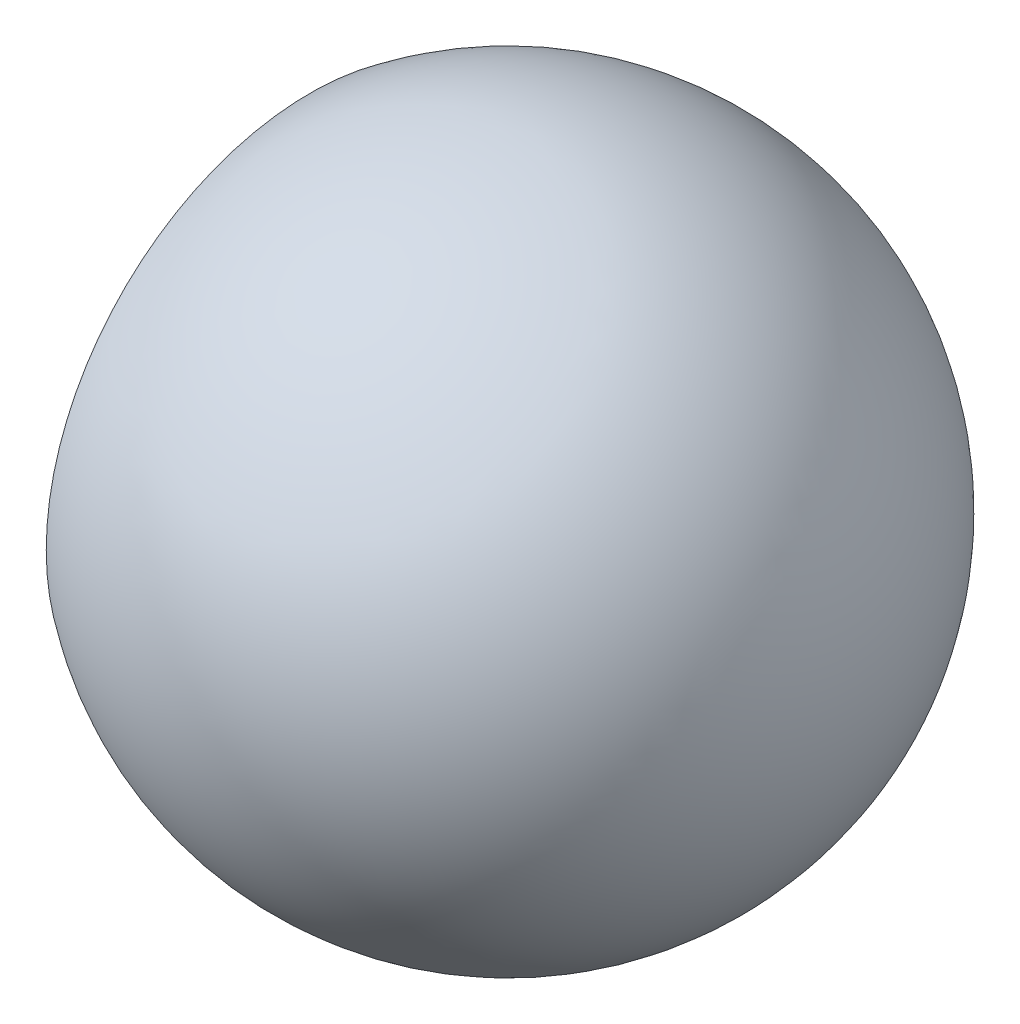
from build123d import *


with BuildPart() as part:
    # Эскиз5 → Повернуть2 (revolve)
    with BuildSketch(Plane.XY):
        with BuildLine():
            Line((0, 0), (10, 0))
            ThreePointArc((10, 0), (4.472135955, -8.94427191), (-6, -8))
            Line((-6, -8), (-6, 0))
            Line((-6, 0), (0, 0))
        make_face()
    revolve(axis=Axis((0, 0, 0), (1, 0, 0)))


solid = part.part
